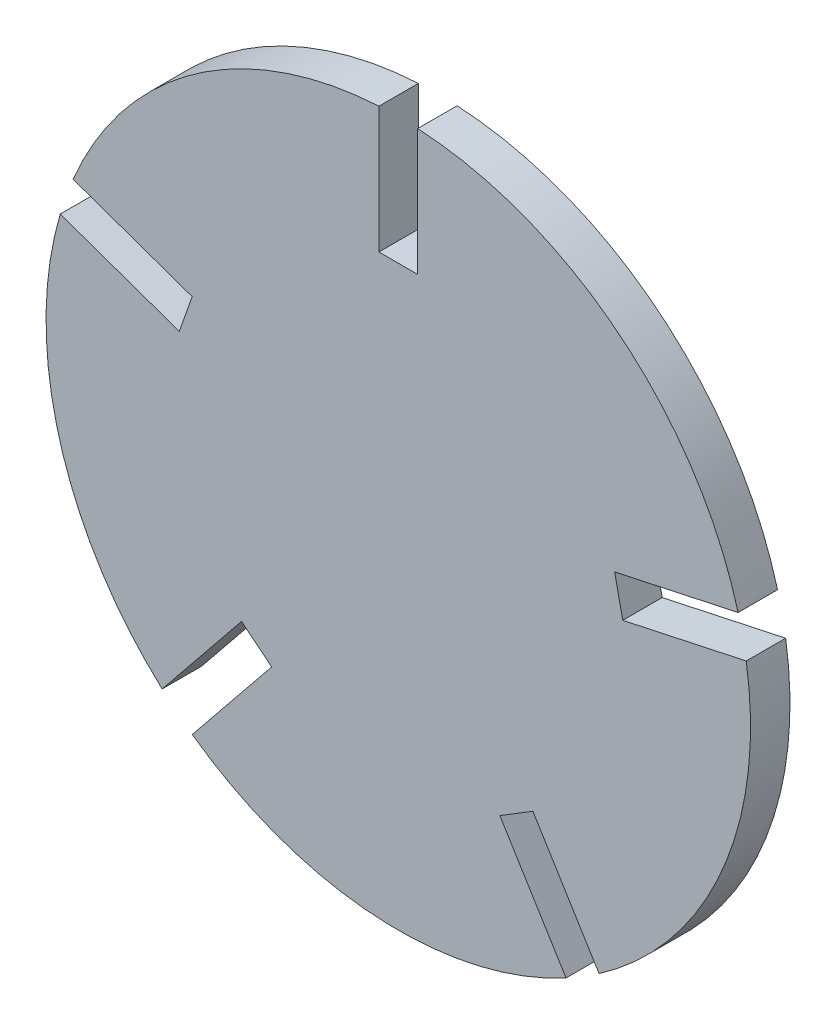
from build123d import *

# Parameters (mm, degrees)
CROQUIS1_R              = 25
SALIENTE_EXTRUIR1_DEPTH = 2.8
CROQUIS2_W              = 2.75
CROQUIS2_H              = 18
CORTAR_EXTRUIR1_DEPTH   = 3.8
MATRIZC2_COUNT          = 5
MATRIZC2_ANGLE          = 282.12


with BuildPart() as part:
    # Croquis1 → Saliente-Extruir1 (new body)
    with BuildSketch(Plane.XY):
        Circle(CROQUIS1_R)
    extrude(amount=SALIENTE_EXTRUIR1_DEPTH)

    # Croquis2 → Cortar-Extruir1 (cut, through all)
    with BuildSketch(Plane.XY):
        with Locations((0, 25)):
            Rectangle(CROQUIS2_W, CROQUIS2_H)
    cortar_extruir1 = extrude(amount=CORTAR_EXTRUIR1_DEPTH, mode=Mode.SUBTRACT)

    # MatrizC2: Cortar-Extruir1 ×5 about axis
    matrizc2_axis = Axis((0, 0, 0), (0, 0, 1))
    for i in range(1, MATRIZC2_COUNT):
        add(cortar_extruir1.rotate(matrizc2_axis, i * MATRIZC2_ANGLE / (MATRIZC2_COUNT - 1)), mode=Mode.SUBTRACT)


solid = part.part
